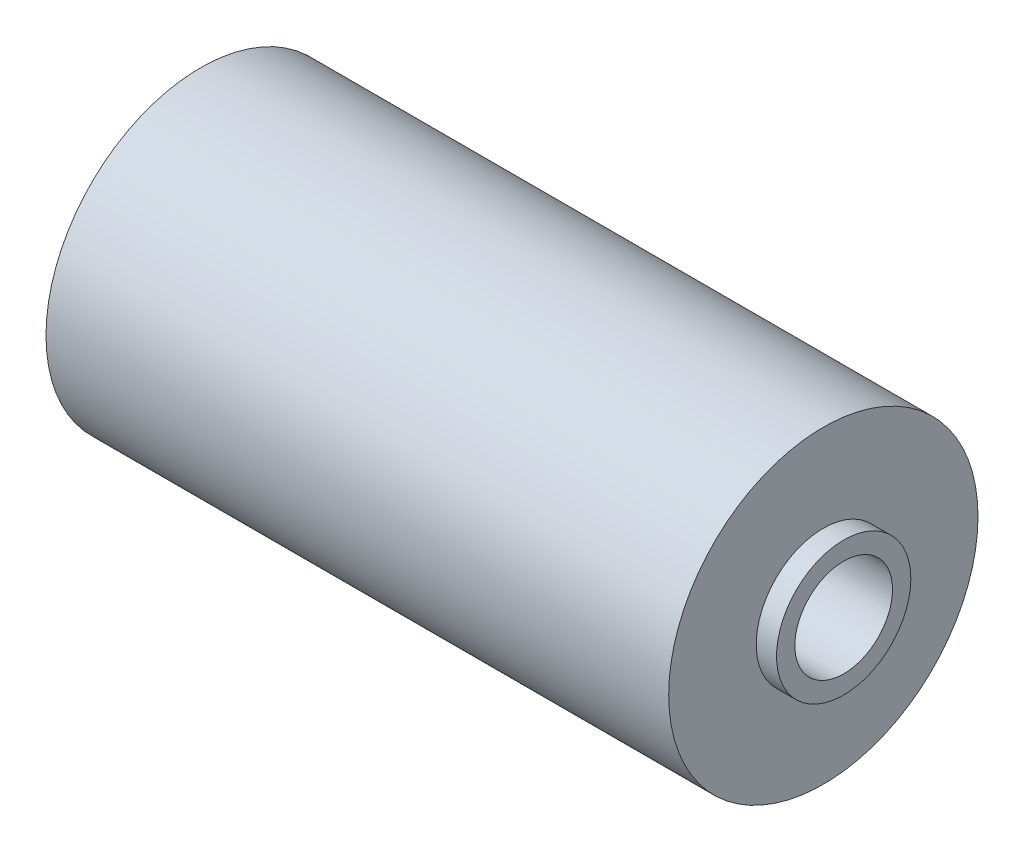
from build123d import *

# Parameters (mm, degrees)
SKETCH1_R               = 16.5
SKETCH1_R_2             = 12
BOSS_EXTRUDE1_DEPTH     = 81.5
BOSS_EXTRUDE2_START     = -5
SKETCH2_R               = 38
BOSS_EXTRUDE2_DEPTH     = 153
SKETCH3_R               = 12
CUT_EXTRUDE1_DEPTH      = 167.88918479
CUT_EXTRUDE1_DEPTH_BACK = 167.88918479


with BuildPart() as part:
    # Sketch1 → Boss-Extrude1 (new, symmetric)
    with BuildSketch(Plane(origin=(0, 0, 0), x_dir=(0, 0, -1), z_dir=(1, 0, 0))):
        Circle(SKETCH1_R)
        Circle(SKETCH1_R_2, mode=Mode.SUBTRACT)
    extrude(amount=BOSS_EXTRUDE1_DEPTH, both=True)

    # Sketch2 → Boss-Extrude2 (add)
    with BuildSketch(Plane.ZY.offset(81.5).offset(BOSS_EXTRUDE2_START)):
        Circle(SKETCH2_R)
    extrude(amount=-BOSS_EXTRUDE2_DEPTH)

    # Sketch3 → Cut-Extrude1 (cut, two sides)
    with BuildSketch(Plane.ZY.offset(76.5)) as cut_extrude1_sk:
        with Locations(Location((0, 0, 0), (0, 0, 180))):
            Circle(SKETCH3_R)
    extrude(amount=CUT_EXTRUDE1_DEPTH, mode=Mode.SUBTRACT)
    extrude(cut_extrude1_sk.sketch, amount=-CUT_EXTRUDE1_DEPTH_BACK, mode=Mode.SUBTRACT)


solid = part.part
